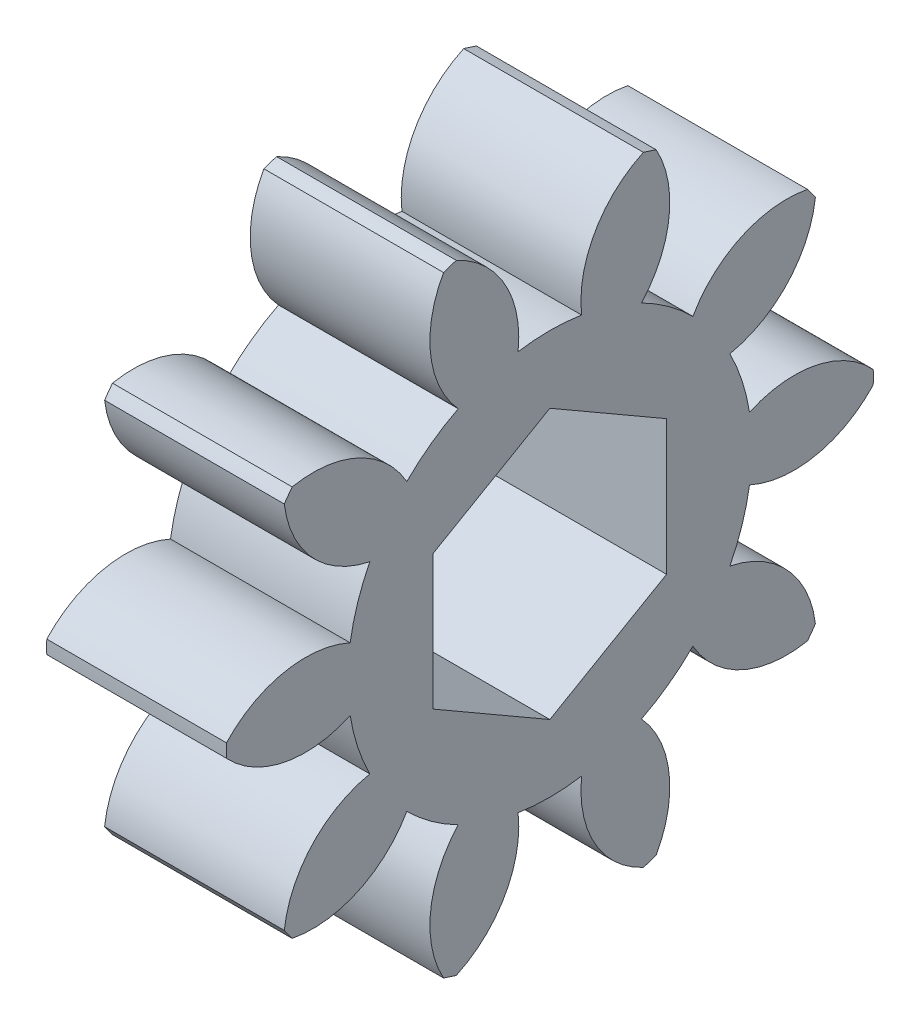
from build123d import *

# Parameters (mm, degrees)
BASPROSKE_W     = 5
BASPROSKE_H     = 9
TOOTHCUT_DEPTH  = 14.674794331
TEETHCUTS_COUNT = 10
TEETHCUTS_ANGLE = 324
BORE_DEPTH      = 50.0003048


with BuildPart() as part:
    # BasProSke → Base-Revolve (revolve)
    with BuildSketch(Plane(origin=(0, 0, 0), x_dir=(1, 0, 0), z_dir=(0, 1, 0)), mode=Mode.PRIVATE) as base_revolve_sk:
        with Locations((2.5, 4.5)):
            Rectangle(BASPROSKE_W, BASPROSKE_H)
    revolve(base_revolve_sk.sketch.rotate(Axis((-10, 0, 0), (1, 0, 0)), 180), axis=Axis((-10, 0, 0), (1, 0, 0)))

    # TooCutSke → ToothCut (cut, through all)
    with BuildSketch(Plane(origin=(0, 0, 0), x_dir=(0, 0, -1), z_dir=(1, 0, 0))):
        with BuildLine():
            ThreePointArc((0.883878355, 5.554109745), (0, 5.624), (-0.883878355, 5.554109745))
            ThreePointArc((-0.883878355, 5.554109745), (-1.258245767, 7.379188248), (-2.637816971, 8.631324741))
            ThreePointArc((-2.637816971, 8.631324741), (0, 9.0254), (2.637816971, 8.631324741))
            ThreePointArc((2.637816971, 8.631324741), (1.258245767, 7.379188248), (0.883878355, 5.554109745))
        make_face()
    toothcut = extrude(amount=TOOTHCUT_DEPTH, mode=Mode.SUBTRACT)

    # TeethCuts: ToothCut ×10 about axis
    teethcuts_axis = Axis((-10, 0, 0), (1, 0, 0))
    for i in range(1, TEETHCUTS_COUNT):
        add(toothcut.rotate(teethcuts_axis, i * TEETHCUTS_ANGLE / (TEETHCUTS_COUNT - 1)), mode=Mode.SUBTRACT)

    # BorSke → Bore (cut, symmetric)
    with BuildSketch(Plane(origin=(0, 0, 0), x_dir=(0, 0, -1), z_dir=(1, 0, 0))):
        Polygon((0, 3.75), (-3.247595264, 1.875), (-3.247595264, -1.875), (0, -3.75), (3.247595264, -1.875), (3.247595264, 1.875), align=None)
    extrude(amount=BORE_DEPTH, both=True, mode=Mode.SUBTRACT)


solid = part.part
